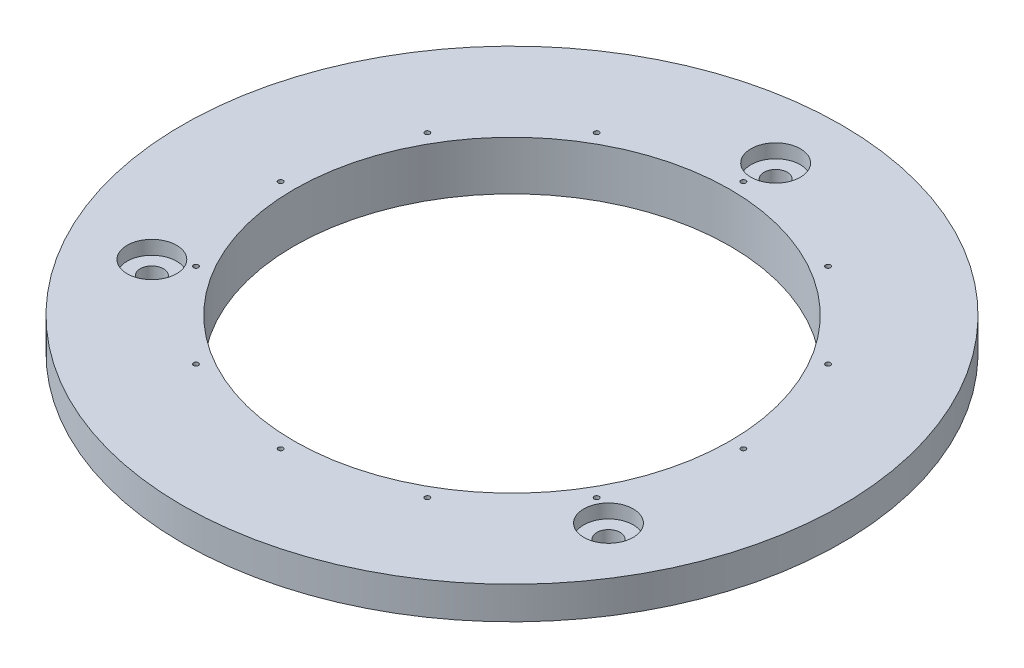
from build123d import *

# Parameters (mm, degrees)
SKETCH2_R                = 63.5
SKETCH2_R_2              = 42.0000049
BOSS_EXTRUDE1_DEPTH      = 9.449999896
SKETCH27_W               = 4.908836101
SKETCH27_H               = 3.175
CIRPATTERN1_COUNT        = 3
M1_2X0_25_TAPPED_HOLE2_D = 0.95
CIRPATTERN2_COUNT        = 12


with BuildPart() as part:
    # Sketch2 → Boss-Extrude1 (new body)
    with BuildSketch(Plane(origin=(0, 0, 0), x_dir=(1, 0, 0), z_dir=(0, 1, 0))):
        Circle(SKETCH2_R)
        Circle(SKETCH2_R_2, mode=Mode.SUBTRACT)
    extrude(amount=BOSS_EXTRUDE1_DEPTH)

    # Sketch27 → Cut-Revolve1 (revolve, cut)
    with BuildSketch(Plane.XY):
        with Locations((61.04558195, 1.5875)):
            Rectangle(SKETCH27_W, SKETCH27_H)
    revolve(axis=Axis((0, 0, 0), (0, 1, 0)), mode=Mode.SUBTRACT)

    # Sketch33 → CBORE for _8 Binding Head Machine Screw1 (revolve, cut)
    with BuildSketch(Plane(origin=(0, 9.449999896, -50.8), x_dir=(0, 0, 1), z_dir=(1, 0, 0))):
        Polygon((0, 0), (0, 503.000674586), (2.2479, 501.65), (2.2479, 2.667), (4.7625, 2.667), (4.7625, 0), align=None)
    cbore_for_8_binding_head_machine_screw1 = revolve(axis=Axis((0, 15.799999896, -50.8), (0, -1, 0)), mode=Mode.SUBTRACT)

    # CirPattern1: CBORE for _8 Binding Head Machine Screw1 ×3 about axis
    cirpattern1_axis = Axis((0, 9.449999896, 0), (0, -1, 0))
    for i in range(1, CIRPATTERN1_COUNT):
        add(cbore_for_8_binding_head_machine_screw1.rotate(cirpattern1_axis, i * 360 / CIRPATTERN1_COUNT), mode=Mode.SUBTRACT)

    # M1.2x0.25 Tapped Hole2 (through all)
    with Locations(Plane(origin=(0, 9.449999896, -44.579871472), x_dir=(0, 0, 1), z_dir=(0, 1, 0))):
        with Locations((0, 0)):
            m1_2x0_25_tapped_hole2 = Hole(M1_2X0_25_TAPPED_HOLE2_D / 2)

    # CirPattern2: M1.2x0.25 Tapped Hole2 ×12 about axis
    cirpattern2_axis = Axis((0, 9.449999896, 0), (0, -1, 0))
    for i in range(1, CIRPATTERN2_COUNT):
        add(m1_2x0_25_tapped_hole2.rotate(cirpattern2_axis, i * 360 / CIRPATTERN2_COUNT), mode=Mode.SUBTRACT)


solid = part.part
